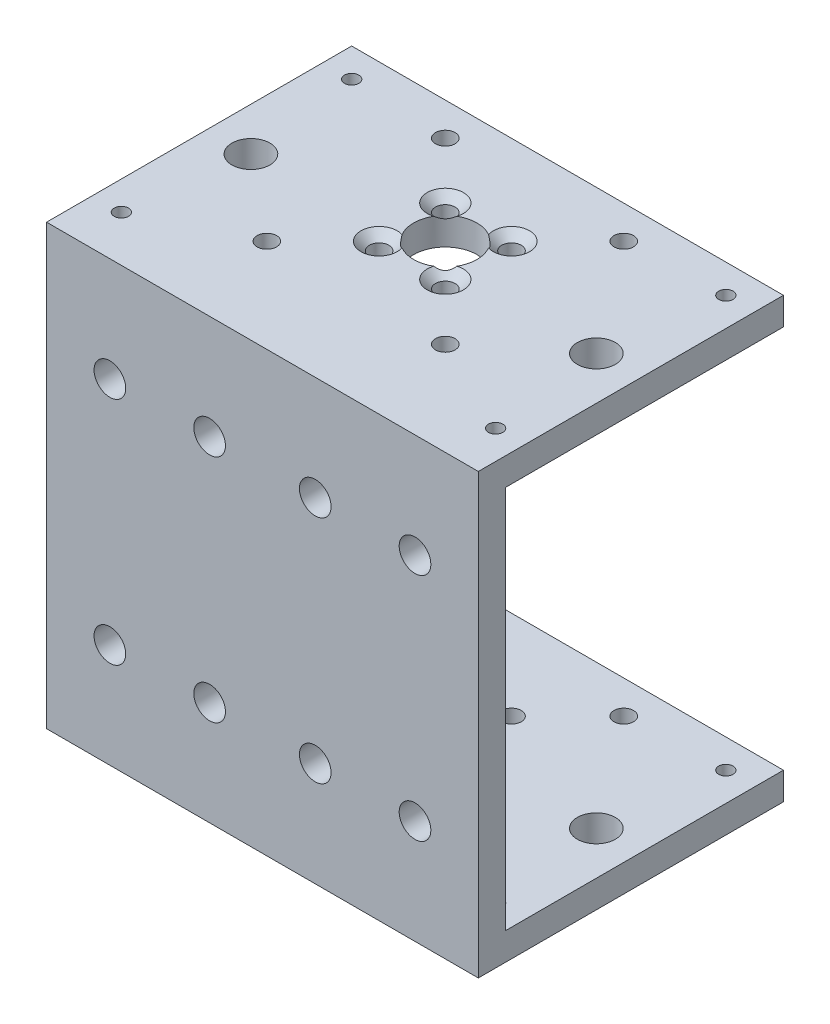
from build123d import *

# Parameters (mm, degrees)
EXTRUDE_THIN1_DEPTH                            = 37.5
SKETCH4_R                                      = 5.5
CUT_EXTRUDE1_DEPTH                             = 72.4375
CUT_EXTRUDE1_DEPTH_BACK                        = 5.7625
M5_CLEARANCE_HOLE1_D                           = 5.5
M6_CLEARANCE_HOLE2_D                           = 6.6
CSK_FOR_M3_FLAT_HEAD_MACHINE_SCREW1_AT_2_COUNT = 2
CSK_FOR_M3_FLAT_HEAD_MACHINE_SCREW1_AT_2_PITCH = 11.5
CSK_FOR_M3_FLAT_HEAD_MACHINE_SCREW1_AT_3_COUNT = 2
CSK_FOR_M3_FLAT_HEAD_MACHINE_SCREW1_AT_3_PITCH = 16.263455967
CSK_FOR_M3_FLAT_HEAD_MACHINE_SCREW1_AT_4_COUNT = 2
CSK_FOR_M3_FLAT_HEAD_MACHINE_SCREW1_AT_4_PITCH = 11.5
CSK_FOR_M3_SFHCS2_D                            = 3.4
CSK_FOR_M3_SFHCS2_DEPTH                        = 10
CSK_FOR_M3_SFHCS2_CSINK_D                      = 6.72
CSK_FOR_M3_SFHCS2_CSINK_ANGLE                  = 90
CSK_FOR_M3_SFHCS2_TIP                          = 1.021463052
M3_CLEARANCE_HOLE1_D                           = 3.4
M3X0_5_TAPPED_HOLE2_AT_2_COUNT                 = 2
M3X0_5_TAPPED_HOLE2_AT_2_PITCH                 = 65
M3X0_5_TAPPED_HOLE2_AT_3_COUNT                 = 2
M3X0_5_TAPPED_HOLE2_AT_3_PITCH                 = 76.321687612
M3X0_5_TAPPED_HOLE2_AT_4_COUNT                 = 2
M3X0_5_TAPPED_HOLE2_AT_4_PITCH                 = 40
M5_CLEARANCE_HOLE2_D                           = 5.5


with BuildPart() as part:
    # Sketch3 → Extrude-Thin1 (new body, symmetric)
    with BuildSketch(Plane(origin=(0, 0, 0), x_dir=(0, 0, -1), z_dir=(1, 0, 0))):
        Polygon((53, 0), (0, 0), (0, 76.2), (53, 76.2), (53, 71.4375), (4.7625, 71.4375), (4.7625, 4.7625), (53, 4.7625), align=None)
    extrude(amount=EXTRUDE_THIN1_DEPTH, both=True)

    # Sketch4 → Cut-Extrude1 (cut, two sides)
    with BuildSketch(Plane(origin=(0, 4.7625, 0), x_dir=(1, 0, 0), z_dir=(0, 1, 0))) as cut_extrude1_sk:
        with Locations((0, 31.7625)):
            Circle(SKETCH4_R)
    extrude(amount=CUT_EXTRUDE1_DEPTH, mode=Mode.SUBTRACT)
    extrude(cut_extrude1_sk.sketch, amount=-CUT_EXTRUDE1_DEPTH_BACK, mode=Mode.SUBTRACT)

    # M5 Clearance Hole1 (through all)
    with Locations(Plane.XY):
        with Locations((-26.5, 58.1005), (26.5, 58.1005), (26.5, 18.1005), (-26.5, 18.1005)):
            Hole(M5_CLEARANCE_HOLE1_D / 2)

    # M6 Clearance Hole2 (through all)
    with Locations(Plane(origin=(0, 0, 0), x_dir=(-1, 0, 0), z_dir=(0, -1, 0))):
        with Locations((30, 28), (-30, 28)):
            Hole(M6_CLEARANCE_HOLE2_D / 2)

    # Sketch11 → CSK for M3 Flat Head Machine Screw1 (revolve, cut)
    with BuildSketch(Plane(origin=(-5.75, 0, -26.0125), x_dir=(0, 0, -1), z_dir=(1, 0, 0))):
        Polygon((0, 0), (0, 11.021463052), (1.7, 10), (1.7, 1.45), (3.15, 0), align=None)
    csk_for_m3_flat_head_machine_screw1 = revolve(axis=Axis((-5.75, -6.35, -26.0125), (0, 1, 0)), mode=Mode.SUBTRACT)

    # CSK for M3 Flat Head Machine Screw1 at 2: CSK for M3 Flat Head Machine Screw1 ×2
    with Locations(*[(i * CSK_FOR_M3_FLAT_HEAD_MACHINE_SCREW1_AT_2_PITCH, 0, 0) for i in range(1, CSK_FOR_M3_FLAT_HEAD_MACHINE_SCREW1_AT_2_COUNT)]):
        add(csk_for_m3_flat_head_machine_screw1, mode=Mode.SUBTRACT)

    # CSK for M3 Flat Head Machine Screw1 at 3: CSK for M3 Flat Head Machine Screw1 ×2
    with Locations(*[Vector(0.707106781, 0, -0.707106781) * (i * CSK_FOR_M3_FLAT_HEAD_MACHINE_SCREW1_AT_3_PITCH) for i in range(1, CSK_FOR_M3_FLAT_HEAD_MACHINE_SCREW1_AT_3_COUNT)]):
        add(csk_for_m3_flat_head_machine_screw1, mode=Mode.SUBTRACT)

    # CSK for M3 Flat Head Machine Screw1 at 4: CSK for M3 Flat Head Machine Screw1 ×2
    with Locations(*[(0, 0, -i * CSK_FOR_M3_FLAT_HEAD_MACHINE_SCREW1_AT_4_PITCH) for i in range(1, CSK_FOR_M3_FLAT_HEAD_MACHINE_SCREW1_AT_4_COUNT)]):
        add(csk_for_m3_flat_head_machine_screw1, mode=Mode.SUBTRACT)

    # Mirror1: CSK for M3 Flat Head Machine Screw1 across plane
    add(csk_for_m3_flat_head_machine_screw1.mirror(Plane(origin=(0, 38.1, 0), x_dir=(0, 0, 1), z_dir=(0, -1, 0))), mode=Mode.SUBTRACT)

    # Mirror1 copy 1 sketch → Mirror1 copy 1 (revolve, cut)
    with BuildSketch(Plane(origin=(5.75, 76.2, -26.0125), x_dir=(0, 0, -1), z_dir=(1, 0, 0))):
        Polygon((0, 0), (0, -11.021463052), (1.7, -10), (1.7, -1.45), (3.15, 0), align=None)
    revolve(axis=Axis((5.75, 82.55, -26.0125), (0, 1, 0)), mode=Mode.SUBTRACT)

    # Mirror1 copy 2 sketch → Mirror1 copy 2 (revolve, cut)
    with BuildSketch(Plane(origin=(5.75, 76.2, -37.5125), x_dir=(0, 0, -1), z_dir=(1, 0, 0))):
        Polygon((0, 0), (0, -11.021463052), (1.7, -10), (1.7, -1.45), (3.15, 0), align=None)
    revolve(axis=Axis((5.75, 82.55, -37.5125), (0, 1, 0)), mode=Mode.SUBTRACT)

    # Mirror1 copy 3 sketch → Mirror1 copy 3 (revolve, cut)
    with BuildSketch(Plane(origin=(-5.75, 76.2, -37.5125), x_dir=(0, 0, -1), z_dir=(1, 0, 0))):
        Polygon((0, 0), (0, -11.021463052), (1.7, -10), (1.7, -1.45), (3.15, 0), align=None)
    revolve(axis=Axis((-5.75, 82.55, -37.5125), (0, 1, 0)), mode=Mode.SUBTRACT)

    # CSK for M3 SFHCS2
    with Locations(Plane(origin=(0, 71.4375, 0), x_dir=(-1, 0, 0), z_dir=(0, -1, 0))):
        with Locations((15.5, 47.2625), (15.5, 16.2625), (-15.5, 16.2625), (-15.5, 47.2625)):
            CounterSinkHole(CSK_FOR_M3_SFHCS2_D / 2, CSK_FOR_M3_SFHCS2_CSINK_D / 2, depth=CSK_FOR_M3_SFHCS2_DEPTH, counter_sink_angle=CSK_FOR_M3_SFHCS2_CSINK_ANGLE)
            with Locations((0, 0, -(CSK_FOR_M3_SFHCS2_DEPTH + CSK_FOR_M3_SFHCS2_TIP / 2))):  # 118° drill point
                Cone(0, CSK_FOR_M3_SFHCS2_D / 2, CSK_FOR_M3_SFHCS2_TIP, mode=Mode.SUBTRACT)

    # M3 Clearance Hole1 (through all)
    with Locations(Plane(origin=(0, 76.2, 0), x_dir=(1, 0, 0), z_dir=(0, 1, 0))):
        with Locations((-15.5, 47.2625), (15.5, 47.2625), (15.5, 16.2625), (-15.5, 16.2625)):
            Hole(M3_CLEARANCE_HOLE1_D / 2)

    # Sketch19 → M3x0.5 Tapped Hole2 (revolve, cut)
    with BuildSketch(Plane(origin=(-32.5, 76.2, -48), x_dir=(0, 0, 1), z_dir=(1, 0, 0))):
        Polygon((0, 0), (0, 8.251075774), (1.25, 7.5), (1.25, 0), align=None)
    m3x0_5_tapped_hole2 = revolve(axis=Axis((-32.5, 82.55, -48), (0, -1, 0)), mode=Mode.SUBTRACT)

    # M3x0.5 Tapped Hole2 at 2: M3x0.5 Tapped Hole2 ×2
    with Locations(*[(i * M3X0_5_TAPPED_HOLE2_AT_2_PITCH, 0, 0) for i in range(1, M3X0_5_TAPPED_HOLE2_AT_2_COUNT)]):
        add(m3x0_5_tapped_hole2, mode=Mode.SUBTRACT)

    # M3x0.5 Tapped Hole2 at 3: M3x0.5 Tapped Hole2 ×2
    with Locations(*[Vector(0.851658317, 0, 0.524097426) * (i * M3X0_5_TAPPED_HOLE2_AT_3_PITCH) for i in range(1, M3X0_5_TAPPED_HOLE2_AT_3_COUNT)]):
        add(m3x0_5_tapped_hole2, mode=Mode.SUBTRACT)

    # M3x0.5 Tapped Hole2 at 4: M3x0.5 Tapped Hole2 ×2
    with Locations(*[(0, 0, i * M3X0_5_TAPPED_HOLE2_AT_4_PITCH) for i in range(1, M3X0_5_TAPPED_HOLE2_AT_4_COUNT)]):
        add(m3x0_5_tapped_hole2, mode=Mode.SUBTRACT)

    # Mirror2: M3x0.5 Tapped Hole2 across plane
    add(m3x0_5_tapped_hole2.mirror(Plane(origin=(0, 38.1, 0), x_dir=(0, 0, 1), z_dir=(0, -1, 0))), mode=Mode.SUBTRACT)

    # Mirror2 copy 1 sketch → Mirror2 copy 1 (revolve, cut)
    with BuildSketch(Plane(origin=(32.5, 0, -48), x_dir=(0, 0, 1), z_dir=(1, 0, 0))):
        Polygon((0, 0), (0, -8.251075774), (1.25, -7.5), (1.25, 0), align=None)
    revolve(axis=Axis((32.5, -6.35, -48), (0, -1, 0)), mode=Mode.SUBTRACT)

    # Mirror2 copy 2 sketch → Mirror2 copy 2 (revolve, cut)
    with BuildSketch(Plane(origin=(32.5, 0, -8), x_dir=(0, 0, 1), z_dir=(1, 0, 0))):
        Polygon((0, 0), (0, -8.251075774), (1.25, -7.5), (1.25, 0), align=None)
    revolve(axis=Axis((32.5, -6.35, -8), (0, -1, 0)), mode=Mode.SUBTRACT)

    # Mirror2 copy 3 sketch → Mirror2 copy 3 (revolve, cut)
    with BuildSketch(Plane(origin=(-32.5, 0, -8), x_dir=(0, 0, 1), z_dir=(1, 0, 0))):
        Polygon((0, 0), (0, -8.251075774), (1.25, -7.5), (1.25, 0), align=None)
    revolve(axis=Axis((-32.5, -6.35, -8), (0, -1, 0)), mode=Mode.SUBTRACT)

    # M5 Clearance Hole2 (through all)
    with Locations(Plane.XY):
        with Locations((-9.175, 18.1), (-9.175, 58.1), (9.175, 58.1), (9.175, 18.1)):
            Hole(M5_CLEARANCE_HOLE2_D / 2)


solid = part.part
